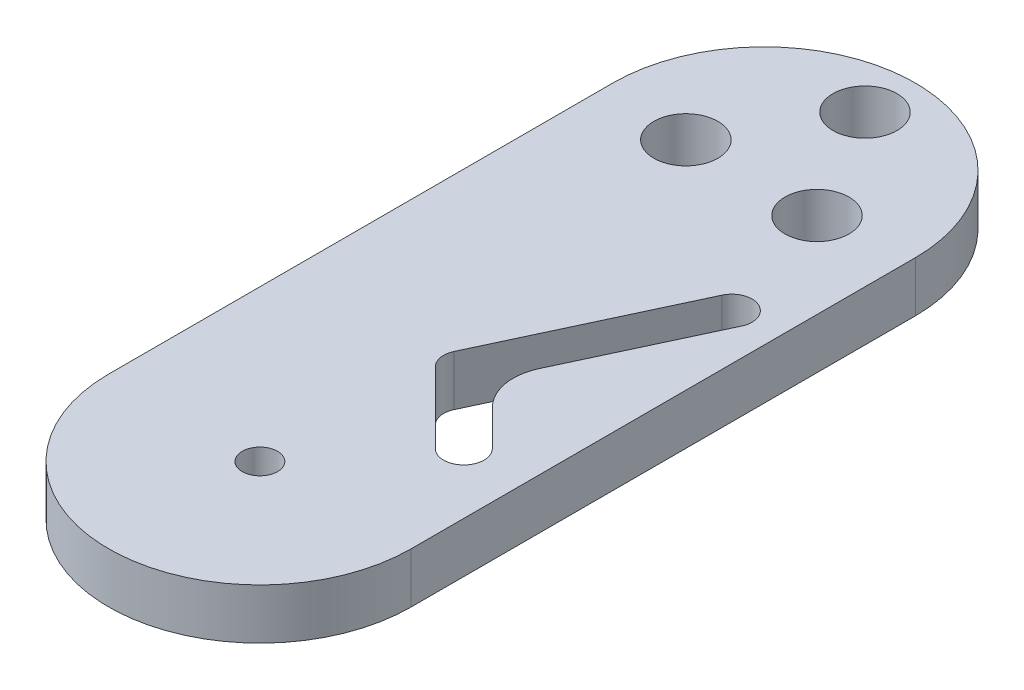
from build123d import *

# Parameters (mm, degrees)
SKETCH1_R           = 3.175
SKETCH1_R_2         = 1.75
BOSS_EXTRUDE1_DEPTH = 5
FILLET1_R           = 5


with BuildPart() as part:
    # Sketch1 → Boss-Extrude1 (new body)
    with BuildSketch(Plane(origin=(0, 0, 0), x_dir=(1, 0, 0), z_dir=(0, 1, 0))):
        with BuildLine():
            Line((15, 0), (15, 50))
            ThreePointArc((15, 50), (0, 65), (-15, 50))
            Line((-15, 50), (-15, 0))
            ThreePointArc((-15, 0), (0, -15), (15, 0))
        make_face()
        with Locations((6.5, 48.741669751)):
            Circle(SKETCH1_R, mode=Mode.SUBTRACT)
        with Locations((-6.5, 48.741669751)):
            Circle(SKETCH1_R, mode=Mode.SUBTRACT)
        with Locations((0, 60)):
            Circle(SKETCH1_R, mode=Mode.SUBTRACT)
        Circle(SKETCH1_R_2, mode=Mode.SUBTRACT)
        with BuildLine():
            ThreePointArc((7.585786438, 9.807118725), (10.414213562, 9.807118725), (10.414213562, 12.63554585))
            Line((10.414213562, 12.63554585), (4.397206201, 18.652553211))
            Line((4.397206201, 18.652553211), (12.25773045, 35.509501863))
            ThreePointArc((12.25773045, 35.509501863), (11.2903514, 38.167353961), (8.632499302, 37.19997491))
            Line((8.632499302, 37.19997491), (0.180134067, 19.07381917))
            ThreePointArc((0.180134067, 19.07381917), (0.023134135, 17.881286291), (0.578536079, 16.814369084))
            Line((0.578536079, 16.814369084), (7.585786438, 9.807118725))
        make_face(mode=Mode.SUBTRACT)
    extrude(amount=BOSS_EXTRUDE1_DEPTH)

    # Fillet1
    fillet1_edges = [part.edges().sort_by_distance(p)[0] for p in [
        (4.397206201, 2.5, -18.652553211),
    ]]
    fillet(fillet1_edges, radius=FILLET1_R)


solid = part.part
